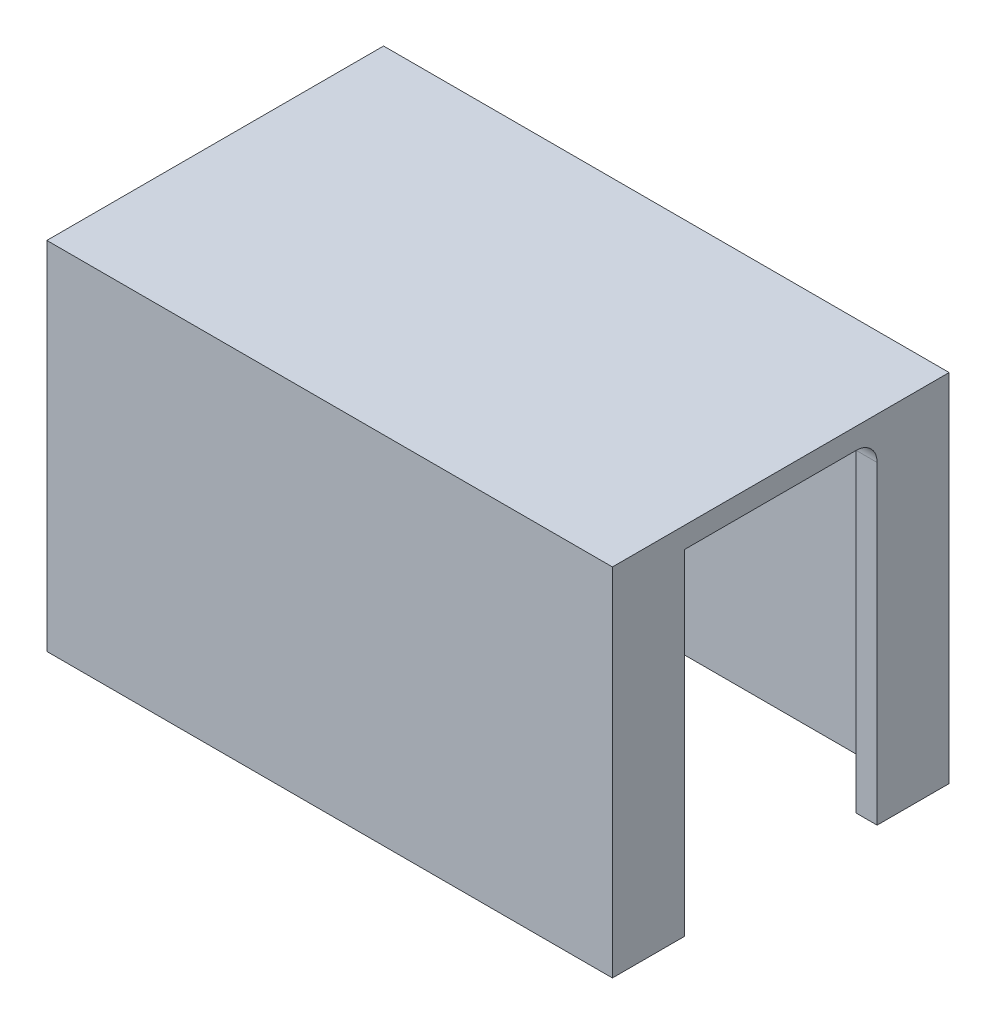
from build123d import *

# Parameters (mm, degrees)
SKETCH1_W           = 85.7504
SKETCH1_H           = 53.975
BOSS_EXTRUDE1_DEPTH = 51.054
SKETCH2_W           = 29.21
SKETCH2_H           = 50.8
CUT_EXTRUDE1_DEPTH  = 114.458991011
SKETCH3_W           = 79.4004
SKETCH3_H           = 50.8
CUT_EXTRUDE2_DEPTH  = 7.747
SKETCH4_W           = 79.4004
SKETCH4_H           = 7.747
CUT_EXTRUDE3_DEPTH  = 50.8
FILLET2_R           = 3.175
FILLET3_R           = 3.175
FILLET4_R           = 3.175
FILLET5_R           = 3.175
FILLET6_R           = 3.175


with BuildPart() as part:
    # Sketch1 → Boss-Extrude1 (new body)
    with BuildSketch(Plane(origin=(0, 0, 0), x_dir=(-1, 0, 0), z_dir=(0, 0, -1))):
        with Locations((-42.8752, 26.9875)):
            Rectangle(SKETCH1_W, SKETCH1_H)
    extrude(amount=-BOSS_EXTRUDE1_DEPTH)

    # Sketch2 → Cut-Extrude1 (cut, through all)
    with BuildSketch(Plane.ZY):
        with Locations((25.527, 25.4)):
            Rectangle(SKETCH2_W, SKETCH2_H)
    extrude(amount=-CUT_EXTRUDE1_DEPTH, mode=Mode.SUBTRACT)

    # Sketch3 → Cut-Extrude2 (cut)
    with BuildSketch(Plane.XY.offset(10.922)):
        with Locations((42.8752, 25.4)):
            Rectangle(SKETCH3_W, SKETCH3_H)
    extrude(amount=-CUT_EXTRUDE2_DEPTH, mode=Mode.SUBTRACT)

    # Sketch4 → Cut-Extrude3 (cut)
    with BuildSketch(Plane.XZ):
        with Locations((42.8752, 44.0055)):
            Rectangle(SKETCH4_W, SKETCH4_H)
    extrude(amount=-CUT_EXTRUDE3_DEPTH, mode=Mode.SUBTRACT)

    # Fillet2
    fillet2_edges = [part.edges().sort_by_distance(p)[0] for p in [
        (3.175, 25.4, 3.175),
    ]]
    fillet(fillet2_edges, radius=FILLET2_R)

    # Fillet3
    fillet3_edges = [part.edges().sort_by_distance(p)[0] for p in [
        (44.4627, 50.8, 3.175),
        (3.175, 50.8, 8.636),
        (4.10493597, 50.8, 4.10493597),
    ]]
    fillet(fillet3_edges, radius=FILLET3_R)

    # Fillet4
    fillet4_edges = [part.edges().sort_by_distance(p)[0] for p in [
        (3.175, 50.8, 10.922),
    ]]
    fillet(fillet4_edges, radius=FILLET4_R)

    # Fillet5
    fillet5_edges = [part.edges().sort_by_distance(p)[0] for p in [
        (82.5754, 23.8125, 3.175),
        (82.5754, 50.8, 8.636),
        (82.5754, 49.87006403, 4.10493597),
    ]]
    fillet(fillet5_edges, radius=FILLET5_R)

    # Fillet6
    fillet6_edges = [part.edges().sort_by_distance(p)[0] for p in [
        (82.5754, 50.8, 10.922),
    ]]
    fillet(fillet6_edges, radius=FILLET6_R)


solid = part.part
